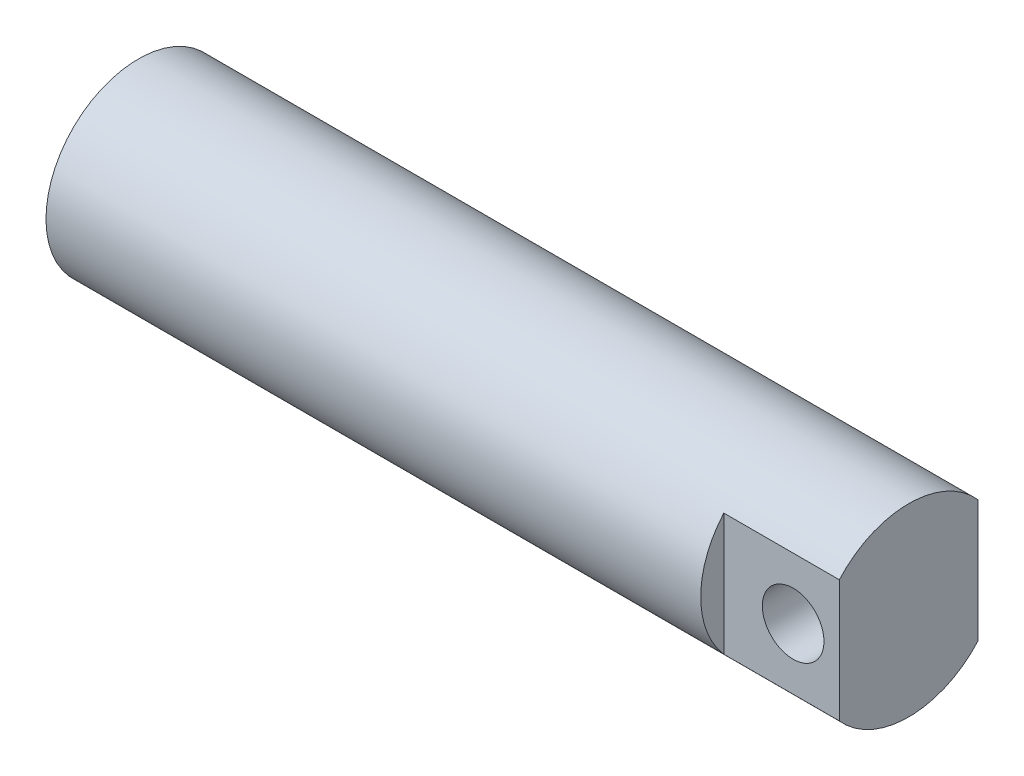
from build123d import *

# Parameters (mm, degrees)
SKETCH2_R           = 38.1
BOSS_EXTRUDE1_DEPTH = 158.75
CUT_EXTRUDE1_DEPTH  = 47.625
SKETCH4_R           = 12.7
CUT_EXTRUDE2_DEPTH  = 67.675


with BuildPart() as part:
    # Sketch2 → Boss-Extrude1 (new body, symmetric)
    with BuildSketch(Plane(origin=(0, 0, 0), x_dir=(0, 0, -1), z_dir=(1, 0, 0))):
        Circle(SKETCH2_R)
    extrude(amount=BOSS_EXTRUDE1_DEPTH, both=True)

    # Sketch3 → Cut-Extrude1 (cut)
    with BuildSketch(Plane(origin=(158.75, 0, 0), x_dir=(0, 0, -1), z_dir=(1, 0, 0))):
        with BuildLine():
            Line((-28.575, 25.200781238), (-28.575, -25.200781238))
            ThreePointArc((-28.575, -25.200781238), (-38.1, 0), (-28.575, 25.200781238))
        make_face()
        with BuildLine():
            Line((28.575, 25.200781238), (28.575, -25.200781238))
            ThreePointArc((28.575, -25.200781238), (38.1, 0), (28.575, 25.200781238))
        make_face()
    extrude(amount=-CUT_EXTRUDE1_DEPTH, mode=Mode.SUBTRACT)

    # Sketch4 → Cut-Extrude2 (cut, through all)
    with BuildSketch(Plane.XY.offset(28.575)):
        with Locations((139.7, 0)):
            Circle(SKETCH4_R)
    extrude(amount=-CUT_EXTRUDE2_DEPTH, mode=Mode.SUBTRACT)


solid = part.part
